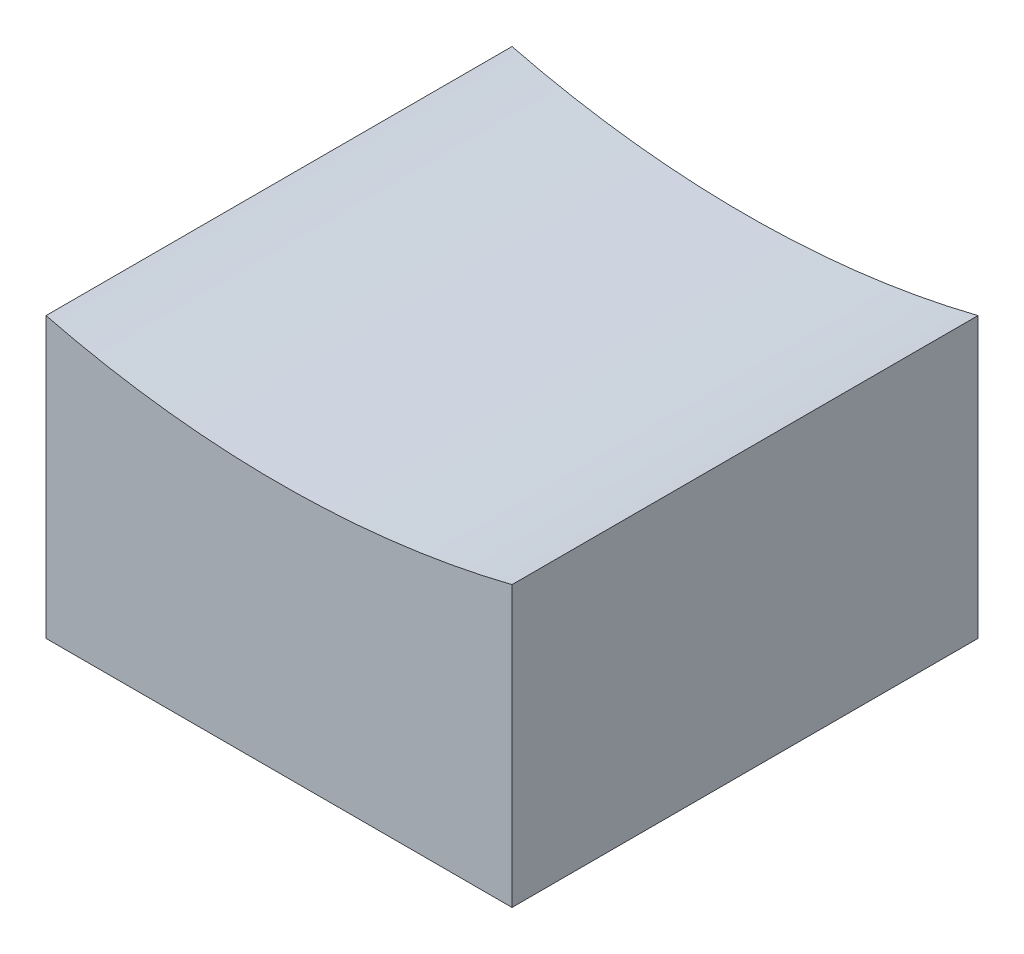
from build123d import *

# Parameters (mm, degrees)
BOSS_EXTRUDE1_DEPTH = 5


with BuildPart() as part:
    # Sketch1 → Boss-Extrude1 (new body)
    with BuildSketch(Plane.XY):
        with BuildLine():
            Line((-2.5, 0), (2.5, 0))
            Line((2.5, 0), (2.5, 3))
            ThreePointArc((2.5, 3), (0, 2.691397622), (-2.5, 3))
            Line((-2.5, 3), (-2.5, 0))
        make_face()
    extrude(amount=BOSS_EXTRUDE1_DEPTH)


solid = part.part
